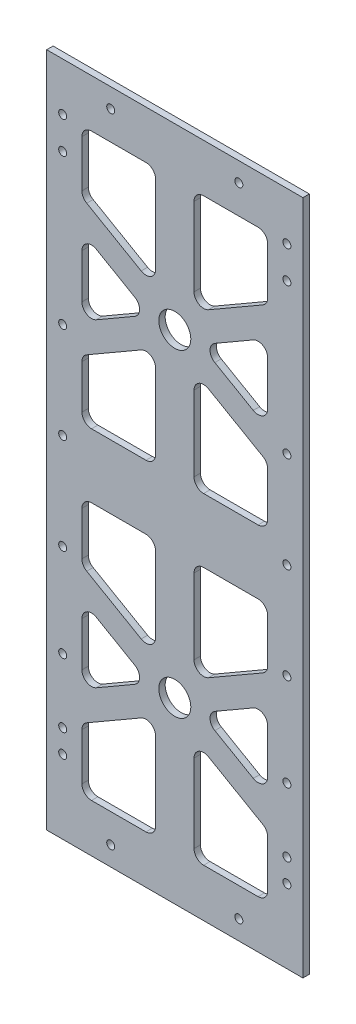
from build123d import *

# Parameters (mm, degrees)
SKETCH1_W                 = 88
SKETCH1_H                 = 211
BOSS_EXTRUDE1_DEPTH       = 2
CUT_EXTRUDE2_DEPTH        = 2
SKETCH4_R                 = 5
CUT_EXTRUDE3_DEPTH        = 3
FILLET2_R                 = 3
SKETCH23_W                = 2
SKETCH23_H                = 211
SKETCH23_W_2              = 2.150374681
CUT_EXTRUDE5_DEPTH        = 10
SKETCH29_W                = 5.911493913
SKETCH29_H                = 211
SKETCH29_W_2              = 4.036537762
CUT_EXTRUDE10_DEPTH       = 2
M3X0_5_TAPPED_HOLE1_D     = 2.5
M3X0_5_TAPPED_HOLE1_DEPTH = 10
M3X0_5_TAPPED_HOLE1_TIP   = 0.751075774


with BuildPart() as part:
    # Sketch1 → Boss-Extrude1 (new body)
    with BuildSketch(Plane.XY):
        with Locations((44, 105.5)):
            Rectangle(SKETCH1_W, SKETCH1_H)
    extrude(amount=BOSS_EXTRUDE1_DEPTH)

    # Sketch3 → Cut-Extrude2 (cut)
    with BuildSketch(Plane.XY.offset(2)):
        Polygon((73, 133.88804004), (50, 147.167096231), (50, 115.5), (73, 115.5), align=None)
        Polygon((38, 115.5), (38, 147.167096231), (15, 133.88804004), (15, 115.5), align=None)
        Polygon((15, 143.125644347), (36, 155.25), (15, 167.374355653), align=None)
        Polygon((73, 143.125644347), (73, 167.374355653), (52, 155.25), align=None)
        Polygon((73, 196), (50, 196), (50, 163.332903769), (73, 176.61195996), align=None)
        Polygon((38, 163.332903769), (38, 196), (15, 196), (15, 176.61195996), align=None)
    cut_extrude2 = extrude(amount=-CUT_EXTRUDE2_DEPTH, mode=Mode.SUBTRACT)

    # Sketch4 → Cut-Extrude3 (cut, through all)
    with BuildSketch(Plane.XY.offset(2)):
        with Locations((44, 155.25)):
            Circle(SKETCH4_R)
    cut_extrude3 = extrude(amount=-CUT_EXTRUDE3_DEPTH, mode=Mode.SUBTRACT)

    # Mirror2: Cut-Extrude2, Cut-Extrude3 across plane
    add(cut_extrude2.mirror(Plane.ZX.offset(105.5)), mode=Mode.SUBTRACT)
    add(cut_extrude3.mirror(Plane.ZX.offset(105.5)), mode=Mode.SUBTRACT)

    # Fillet2
    fillet2_edges = [part.edges().sort_by_distance(p)[0] for p in [
        (36, 55.75, 1),
        (15, 43.625644347, 1),
        (15, 67.874355653, 1),
        (38, 95.5, 1),
        (38, 63.832903769, 1),
        (15, 77.11195996, 1),
        (15, 95.5, 1),
        (73, 15, 1),
        (50, 15, 1),
        (50, 47.667096231, 1),
        (73, 34.38804004, 1),
        (73, 43.625644347, 1),
        (52, 55.75, 1),
        (73, 67.874355653, 1),
        (15, 15, 1),
        (15, 34.38804004, 1),
        (38, 47.667096231, 1),
        (38, 15, 1),
        (73, 77.11195996, 1),
        (50, 63.832903769, 1),
        (50, 95.5, 1),
        (73, 95.5, 1),
        (15, 167.374355653, 1),
        (36, 155.25, 1),
        (15, 143.125644347, 1),
        (38, 147.167096231, 1),
        (38, 115.5, 1),
        (15, 115.5, 1),
        (15, 133.88804004, 1),
        (50, 196, 1),
        (73, 196, 1),
        (73, 176.61195996, 1),
        (50, 163.332903769, 1),
        (52, 155.25, 1),
        (73, 167.374355653, 1),
        (73, 143.125644347, 1),
        (15, 176.61195996, 1),
        (15, 196, 1),
        (38, 196, 1),
        (38, 163.332903769, 1),
        (50, 147.167096231, 1),
        (73, 133.88804004, 1),
        (73, 115.5, 1),
        (50, 115.5, 1),
    ]]
    fillet(fillet2_edges, radius=FILLET2_R)

    # Sketch23 → Cut-Extrude5 (cut)
    with BuildSketch(Plane.XY.offset(2)):
        with Locations((87, 105.5)):
            Rectangle(SKETCH23_W, SKETCH23_H)
        with Locations((1.075187341, 105.5)):
            Rectangle(SKETCH23_W_2, SKETCH23_H)
    extrude(amount=-CUT_EXTRUDE5_DEPTH, mode=Mode.SUBTRACT)

    # Sketch29 → Cut-Extrude10 (cut)
    with BuildSketch(Plane(origin=(0, 0, 0), x_dir=(-1, 0, 0), z_dir=(0, 0, -1))):
        with Locations((-1.044253043, 105.5)):
            Rectangle(SKETCH29_W, SKETCH29_H)
        with Locations((-86.018268881, 105.5)):
            Rectangle(SKETCH29_W_2, SKETCH29_H)
    extrude(amount=-CUT_EXTRUDE10_DEPTH, mode=Mode.SUBTRACT)

    # M3x0.5 Tapped Hole1
    with Locations(Plane.XY.offset(2)):
        with Locations((9, 186), (9, 139.2), (9, 109.2), (9, 79.2), (9, 50.2), (9, 30.2), (79, 186), (79, 139.2), (79, 109.2), (79, 79.2), (79, 50.2), (79, 30.2), (24, 6), (64, 6), (24, 205), (64, 205), (9, 196), (79, 196), (9, 23), (79, 23)):
            Hole(M3X0_5_TAPPED_HOLE1_D / 2, depth=M3X0_5_TAPPED_HOLE1_DEPTH)
            with Locations((0, 0, -(M3X0_5_TAPPED_HOLE1_DEPTH + M3X0_5_TAPPED_HOLE1_TIP / 2))):  # 118° drill point
                Cone(0, M3X0_5_TAPPED_HOLE1_D / 2, M3X0_5_TAPPED_HOLE1_TIP, mode=Mode.SUBTRACT)


solid = part.part
